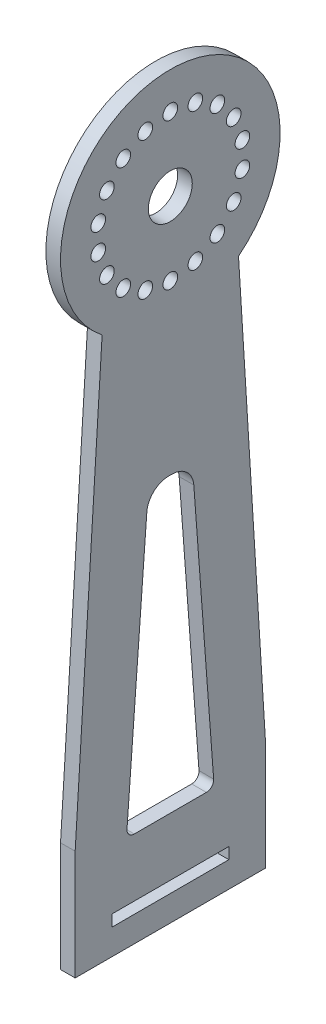
from build123d import *

# Parameters (mm, degrees)
RESSALTO_EXTRUS_O1_DEPTH = 2
ESBO_O2_R                = 3
ESBO_O2_R_2              = 1
CORTE_EXTRUS_O1_DEPTH    = 2
PADR_OCIRCULAR1_COUNT    = 18
ESBO_O3_W                = 16
ESBO_O3_H                = 1.561418551
CORTE_EXTRUS_O2_DEPTH    = 2


with BuildPart() as part:
    # Esboço1 → Ressalto-extrusão1 (new body)
    with BuildSketch(Plane(origin=(0, 0, 0), x_dir=(0, 0, -1), z_dir=(1, 0, 0))):
        with BuildLine():
            Line((-13, -71), (-13, -86))
            Line((-13, -86), (0, -86))
            Line((0, -86), (0, 15))
            ThreePointArc((0, 15), (-14.165790836, 4.932582487), (-9.316524238, -11.755950669))
            add(Edge.make_bspline(
                [(-9.316524238, -11.755950669), (-13, -71)],
                knots=[0, 0, 1, 1], degree=1))
        make_face()
    ressalto_extrus_o1 = extrude(amount=RESSALTO_EXTRUS_O1_DEPTH)

    # Espelhar1: Ressalto-extrusão1 across plane
    add(ressalto_extrus_o1.mirror(Plane(origin=(2, 15, 0), x_dir=(1, 0, 0), z_dir=(0, 0, 1))))

    # Esboço2 → Corte-extrusão1 (cut)
    with BuildSketch(Plane(origin=(2, 0, 0), x_dir=(0, 0, -1), z_dir=(1, 0, 0))):
        Circle(ESBO_O2_R)
        with Locations((0, -10)):
            Circle(ESBO_O2_R_2)
    corte_extrus_o1 = extrude(amount=-CORTE_EXTRUS_O1_DEPTH, mode=Mode.SUBTRACT)

    # PadrãoCircular1: Corte-extrusão1 ×18 about axis
    padr_ocircular1_axis = Axis((0, 0, 0), (1, 0, 0))
    for i in range(1, PADR_OCIRCULAR1_COUNT):
        add(corte_extrus_o1.rotate(padr_ocircular1_axis, i * 360 / PADR_OCIRCULAR1_COUNT), mode=Mode.SUBTRACT)

    # Esboço3 → Corte-extrusão2 (cut)
    with BuildSketch(Plane(origin=(2, 0, 0), x_dir=(0, 0, -1), z_dir=(1, 0, 0))):
        with BuildLine():
            Line((-4.922191444, -73), (4.922191444, -73))
            ThreePointArc((4.922191444, -73), (5.655263728, -72.680150738), (5.919390754, -71.925210052))
            Line((5.919390754, -71.925210052), (3.208172262, -35.775630155))
            ThreePointArc((3.208172262, -35.775630155), (2.257026545, -33.800783147), (0.216574332, -33))
            Line((0.216574332, -33), (-0.216574332, -33))
            ThreePointArc((-0.216574332, -33), (-2.257026545, -33.800783147), (-3.208172262, -35.775630155))
            Line((-3.208172262, -35.775630155), (-5.919390754, -71.925210052))
            ThreePointArc((-5.919390754, -71.925210052), (-5.655263728, -72.680150738), (-4.922191444, -73))
        make_face()
        with Locations((0, -81.719290725)):
            Rectangle(ESBO_O3_W, ESBO_O3_H)
    extrude(amount=-CORTE_EXTRUS_O2_DEPTH, mode=Mode.SUBTRACT)


solid = part.part
